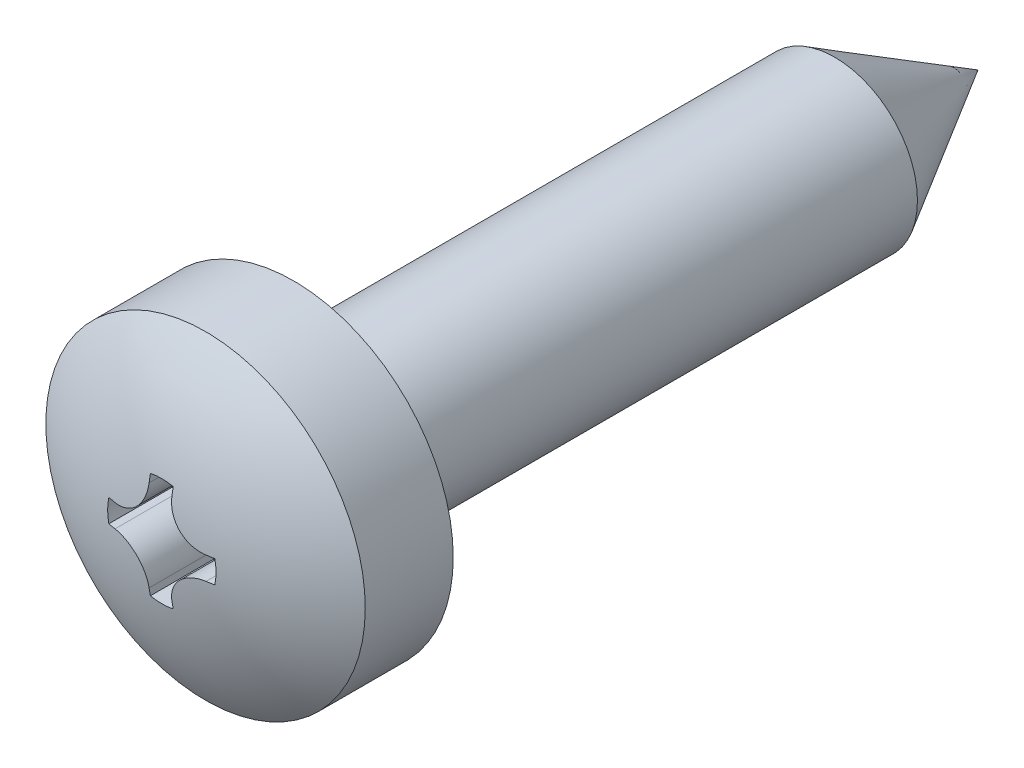
from build123d import *

# Parameters (mm, degrees)
CUT_EXTRUDE_2_DEPTH = 1.2
FILLET_1_R          = 0.1


with BuildPart() as part:
    # 草图8 → Revolve 1380 (revolve)
    with BuildSketch(Plane(origin=(0, 0, 0), x_dir=(0, 0, -1), z_dir=(1, 0, 0))):
        with BuildLine():
            Line((0, 0), (-14.4, 0))
            ThreePointArc((-14.4, 0), (-14.180811394, 1.464186604), (-13.542463035, 2.8))
            Line((-13.542463035, 2.8), (-12, 2.8))
            Line((-12, 2.8), (-12, 1.45))
            Line((-12, 1.45), (-2.511473671, 1.45))
            Line((-2.511473671, 1.45), (0, 0))
        make_face()
    revolve(axis=Axis((0, 0, 11.71), (0, 0, -1)))

    # 草图7 → 切除-拉伸2 (cut)
    with BuildSketch(Plane.XY.offset(14.4)):
        with BuildLine():
            Line((0.2, 0.928708781), (0.2, 0.797500009))
            ThreePointArc((0.2, 0.797500009), (0.375003701, 0.375003701), (0.797500009, 0.2))
            Line((0.797500009, 0.2), (0.928708781, 0.2))
            ThreePointArc((0.928708781, 0.2), (0.95, 0), (0.928708781, -0.2))
            Line((0.928708781, -0.2), (0.797500009, -0.2))
            ThreePointArc((0.797500009, -0.2), (0.375003701, -0.375003701), (0.2, -0.797500009))
            Line((0.2, -0.797500009), (0.2, -0.928708781))
            ThreePointArc((0.2, -0.928708781), (0, -0.95), (-0.2, -0.928708781))
            Line((-0.2, -0.928708781), (-0.2, -0.797500009))
            ThreePointArc((-0.2, -0.797500009), (-0.375003701, -0.375003701), (-0.797500009, -0.2))
            Line((-0.797500009, -0.2), (-0.928708781, -0.2))
            ThreePointArc((-0.928708781, -0.2), (-0.95, 0), (-0.928708781, 0.2))
            Line((-0.928708781, 0.2), (-0.797500009, 0.2))
            ThreePointArc((-0.797500009, 0.2), (-0.375003701, 0.375003701), (-0.2, 0.797500009))
            Line((-0.2, 0.797500009), (-0.2, 0.928708781))
            ThreePointArc((-0.2, 0.928708781), (0, 0.95), (0.2, 0.928708781))
        make_face()
    extrude(amount=-CUT_EXTRUDE_2_DEPTH, mode=Mode.SUBTRACT)

    # 圆角1
    fillet_1_edges = [part.edges().sort_by_distance(p)[0] for p in [
        (0, -1.45, 12),
    ]]
    fillet(fillet_1_edges, radius=FILLET_1_R)


solid = part.part
